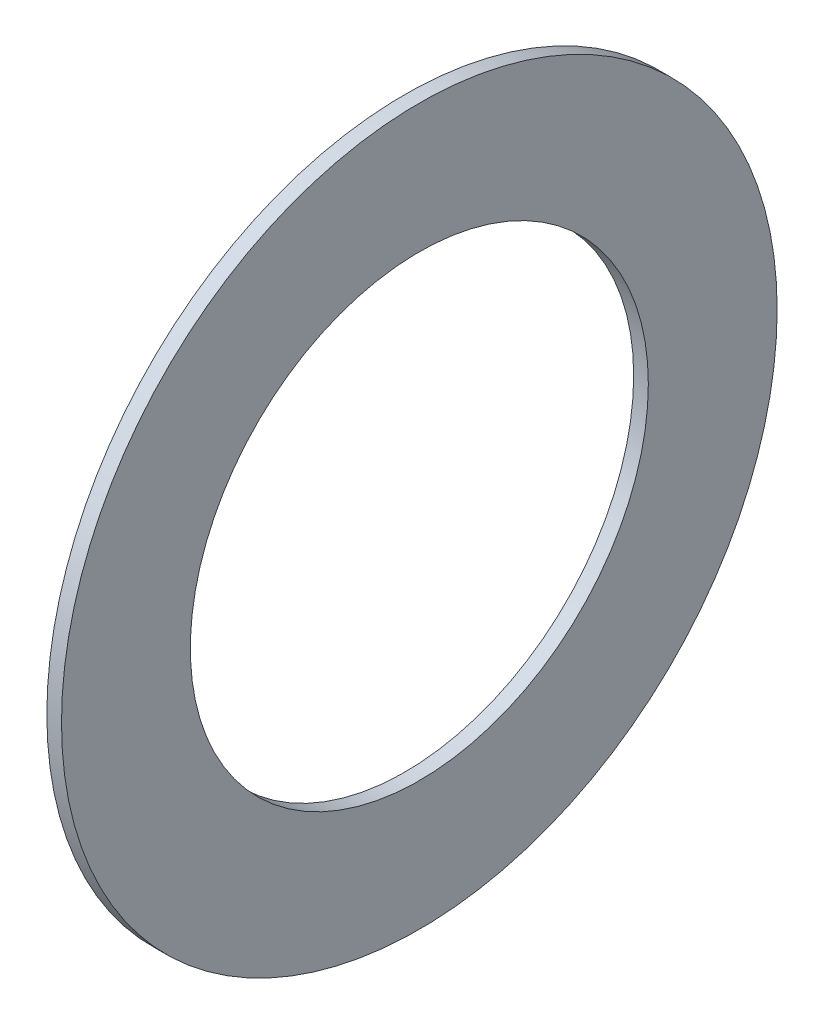
from build123d import *

# Parameters (mm, degrees)
SKETCH1_R      = 19.84375
SKETCH1_R_2    = 12.7
EXTRUDE1_DEPTH = 0.8128


with BuildPart() as part:
    # Sketch1 → Extrude1 (new body)
    with BuildSketch(Plane(origin=(0, 0, 0), x_dir=(0, 0, -1), z_dir=(1, 0, 0))):
        Circle(SKETCH1_R)
        Circle(SKETCH1_R_2, mode=Mode.SUBTRACT)
    extrude(amount=EXTRUDE1_DEPTH)


solid = part.part
